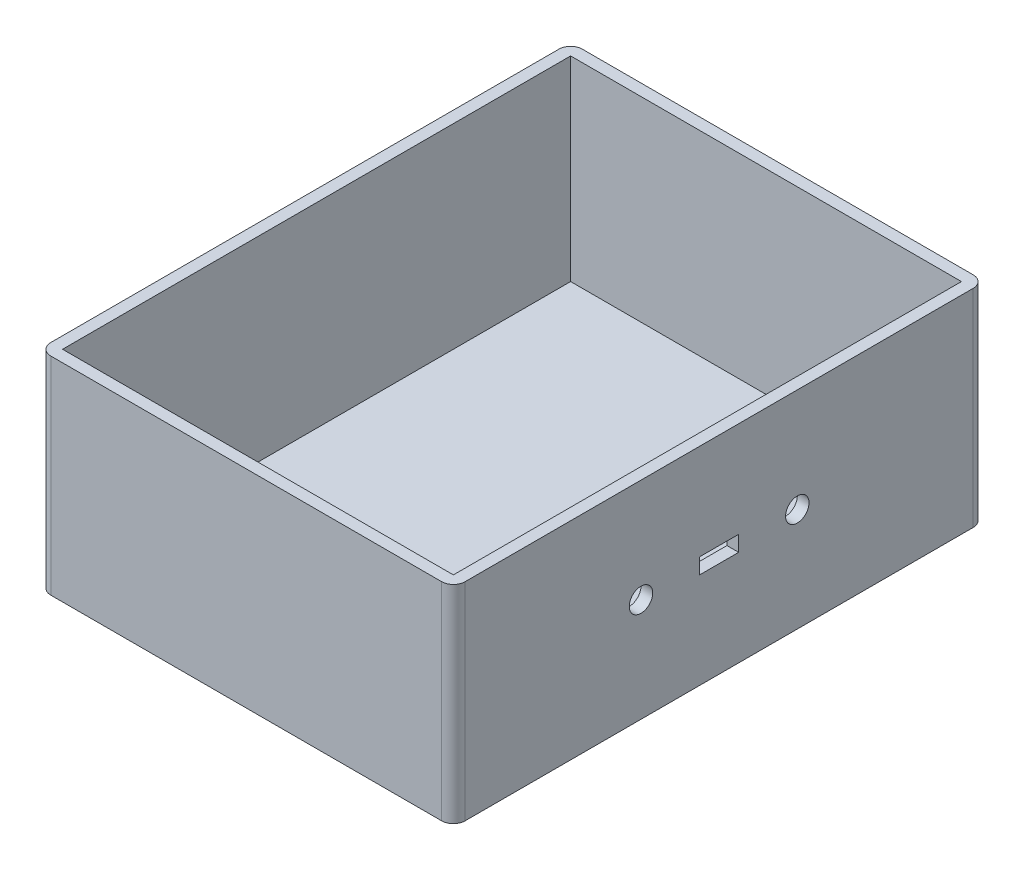
from build123d import *

# Parameters (mm, degrees)
ESQUISSE1_W             = 106
ESQUISSE1_H             = 136
ESQUISSE1_W_2           = 100
ESQUISSE1_H_2           = 130
BOSS_EXTRU_1_DEPTH      = 50
ESQUISSE2_W             = 106
ESQUISSE2_H             = 136
BOSS_EXTRU_2_DEPTH      = 3
CONG_1_R                = 3
ESQUISSE3_R             = 3
ESQUISSE3_W             = 10
ESQUISSE3_H             = 4
ENL_V_MAT_EXTRU_1_DEPTH = 3


with BuildPart() as part:
    # Esquisse1 → Boss.-Extru.1 (new body)
    with BuildSketch(Plane(origin=(0, 0, 0), x_dir=(1, 0, 0), z_dir=(0, 1, 0))):
        Rectangle(ESQUISSE1_W, ESQUISSE1_H)
        Rectangle(ESQUISSE1_W_2, ESQUISSE1_H_2, mode=Mode.SUBTRACT)
    extrude(amount=BOSS_EXTRU_1_DEPTH)

    # Esquisse2 → Boss.-Extru.2 (add)
    with BuildSketch(Plane.XZ):
        Rectangle(ESQUISSE2_W, ESQUISSE2_H)
    extrude(amount=BOSS_EXTRU_2_DEPTH)

    # Congé1
    cong_1_edges = [part.edges().sort_by_distance(p)[0] for p in [
        (53, 23.5, 68),
        (-53, 23.5, 68),
        (-53, 23.5, -68),
        (53, 23.5, -68),
    ]]
    fillet(cong_1_edges, radius=CONG_1_R)

    # Esquisse3 → Enlèv. mat.-Extru.1 (cut)
    with BuildSketch(Plane(origin=(53, 0, 0), x_dir=(0, 0, -1), z_dir=(1, 0, 0))):
        with Locations((-20, 23.5)):
            Circle(ESQUISSE3_R)
        with Locations((20, 23.5)):
            Circle(ESQUISSE3_R)
        with Locations((0, 23.5)):
            Rectangle(ESQUISSE3_W, ESQUISSE3_H)
    extrude(amount=-ENL_V_MAT_EXTRU_1_DEPTH, mode=Mode.SUBTRACT)


solid = part.part
